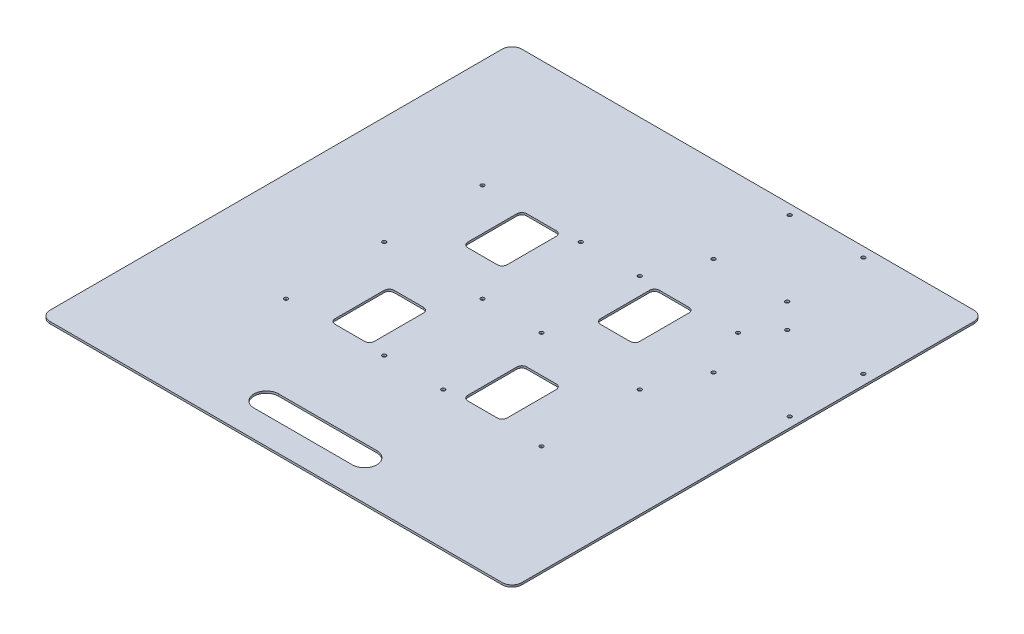
from build123d import *

# Parameters (mm, degrees)
SKETCH1_W                        = 609.6
SKETCH1_H                        = 609.6
BOSS_EXTRUDE1_DEPTH              = 2.65684
CUT_EXTRUDE1_DEPTH               = 3.65684
SKETCH3_R                        = 2.3876
CUT_EXTRUDE2_DEPTH               = 3.65684
LPATTERN1_COUNT                  = 2
LPATTERN1_PITCH                  = 203.2
CUT_EXTRUDE3_DEPTH               = 3.65684
FILLET1_R                        = 12.7
SKETCH5_R                        = 2.3876
CUT_EXTRUDE4_DEPTH               = 3.65684
F_10_0_1935_DIAMETER_HOLE1_D     = 4.9149
F_10_0_1935_DIAMETER_HOLE1_DEPTH = 2.65684


with BuildPart() as part:
    # Sketch1 → Boss-Extrude1 (new body)
    with BuildSketch(Plane(origin=(0, 0, 0), x_dir=(1, 0, 0), z_dir=(0, 1, 0))):
        Rectangle(SKETCH1_W, SKETCH1_H)
    extrude(amount=BOSS_EXTRUDE1_DEPTH)

    # Sketch2 → Cut-Extrude1 (cut, through all)
    with BuildSketch(Plane(origin=(0, 2.65684, 0), x_dir=(1, 0, 0), z_dir=(0, 1, 0))):
        with BuildLine():
            Line((-104.775, 123.825), (-66.675, 123.825))
            ThreePointArc((-66.675, 123.825), (-62.184871939, 121.965128061), (-60.325, 117.475))
            Line((-60.325, 117.475), (-60.325, 53.975))
            ThreePointArc((-60.325, 53.975), (-62.184871939, 49.484871939), (-66.675, 47.625))
            Line((-66.675, 47.625), (-104.775, 47.625))
            ThreePointArc((-104.775, 47.625), (-109.265128061, 49.484871939), (-111.125, 53.975))
            Line((-111.125, 53.975), (-111.125, 117.475))
            ThreePointArc((-111.125, 117.475), (-109.265128061, 121.965128061), (-104.775, 123.825))
        make_face()
        with BuildLine():
            Line((-104.775, -47.625), (-66.675, -47.625))
            ThreePointArc((-66.675, -47.625), (-62.184871939, -49.484871939), (-60.325, -53.975))
            Line((-60.325, -53.975), (-60.325, -117.475))
            ThreePointArc((-60.325, -117.475), (-62.184871939, -121.965128061), (-66.675, -123.825))
            Line((-66.675, -123.825), (-104.775, -123.825))
            ThreePointArc((-104.775, -123.825), (-109.265128061, -121.965128061), (-111.125, -117.475))
            Line((-111.125, -117.475), (-111.125, -53.975))
            ThreePointArc((-111.125, -53.975), (-109.265128061, -49.484871939), (-104.775, -47.625))
        make_face()
        with BuildLine():
            Line((66.675, -47.625), (104.775, -47.625))
            ThreePointArc((104.775, -47.625), (109.265128061, -49.484871939), (111.125, -53.975))
            Line((111.125, -53.975), (111.125, -117.475))
            ThreePointArc((111.125, -117.475), (109.265128061, -121.965128061), (104.775, -123.825))
            Line((104.775, -123.825), (66.675, -123.825))
            ThreePointArc((66.675, -123.825), (62.184871939, -121.965128061), (60.325, -117.475))
            Line((60.325, -117.475), (60.325, -53.975))
            ThreePointArc((60.325, -53.975), (62.184871939, -49.484871939), (66.675, -47.625))
        make_face()
        with BuildLine():
            Line((104.775, 123.825), (66.675, 123.825))
            ThreePointArc((66.675, 123.825), (62.184871939, 121.965128061), (60.325, 117.475))
            Line((60.325, 117.475), (60.325, 53.975))
            ThreePointArc((60.325, 53.975), (62.184871939, 49.484871939), (66.675, 47.625))
            Line((66.675, 47.625), (104.775, 47.625))
            ThreePointArc((104.775, 47.625), (109.265128061, 49.484871939), (111.125, 53.975))
            Line((111.125, 53.975), (111.125, 117.475))
            ThreePointArc((111.125, 117.475), (109.265128061, 121.965128061), (104.775, 123.825))
        make_face()
    extrude(amount=-CUT_EXTRUDE1_DEPTH, mode=Mode.SUBTRACT)

    # Sketch3 → Cut-Extrude2 (cut, through all)
    with BuildSketch(Plane(origin=(0, 2.65684, 0), x_dir=(1, 0, 0), z_dir=(0, 1, 0))):
        with Locations((-165.1, 127)):
            Circle(SKETCH3_R)
        with Locations((-165.1, 0)):
            Circle(SKETCH3_R)
        with Locations((-165.1, -127)):
            Circle(SKETCH3_R)
        with Locations((-38.1, 127)):
            Circle(SKETCH3_R)
        with Locations((-38.1, 0)):
            Circle(SKETCH3_R)
        with Locations((-38.1, -127)):
            Circle(SKETCH3_R)
    cut_extrude2 = extrude(amount=-CUT_EXTRUDE2_DEPTH, mode=Mode.SUBTRACT)

    # LPattern1: Cut-Extrude2 ×2
    with Locations(*[(i * LPATTERN1_PITCH, 0, 0) for i in range(1, LPATTERN1_COUNT)]):
        add(cut_extrude2, mode=Mode.SUBTRACT)

    # Sketch4 → Cut-Extrude3 (cut, through all)
    with BuildSketch(Plane(origin=(0, 2.65684, 0), x_dir=(1, 0, 0), z_dir=(0, 1, 0))):
        with BuildLine():
            Line((-63.5, -238.125), (63.5, -238.125))
            ThreePointArc((63.5, -238.125), (79.375, -254), (63.5, -269.875))
            Line((63.5, -269.875), (-63.5, -269.875))
            ThreePointArc((-63.5, -269.875), (-79.375, -254), (-63.5, -238.125))
        make_face()
    extrude(amount=-CUT_EXTRUDE3_DEPTH, mode=Mode.SUBTRACT)

    # Fillet1
    fillet1_edges = [part.edges().sort_by_distance(p)[0] for p in [
        (304.8, 1.32842, 304.8),
        (-304.8, 1.32842, 304.8),
        (-304.8, 1.32842, -304.8),
        (304.8, 1.32842, -304.8),
    ]]
    fillet(fillet1_edges, radius=FILLET1_R)

    # Sketch5 → Cut-Extrude4 (cut, through all)
    with BuildSketch(Plane(origin=(0, 2.65684, 0), x_dir=(1, 0, 0), z_dir=(0, 1, 0))):
        with Locations((161.925, 292.1)):
            Circle(SKETCH5_R)
        with Locations((66.675, 292.1)):
            Circle(SKETCH5_R)
        with Locations((161.925, 193.675)):
            Circle(SKETCH5_R)
        with Locations((66.675, 193.675)):
            Circle(SKETCH5_R)
        with Locations((193.675, 161.925)):
            Circle(SKETCH5_R)
        with Locations((193.675, 66.675)):
            Circle(SKETCH5_R)
        with Locations((292.1, 66.675)):
            Circle(SKETCH5_R)
        with Locations((292.1, 161.925)):
            Circle(SKETCH5_R)
    extrude(amount=-CUT_EXTRUDE4_DEPTH, mode=Mode.SUBTRACT)

    # #10 (0.1935) Diameter Hole1
    with Locations(Plane(origin=(0, 2.65684, 0), x_dir=(1, 0, 0), z_dir=(0, 1, 0))):
        with Locations((161.925, 292.1), (66.675, 292.1), (292.1, 161.925), (193.675, 161.925), (161.925, 193.675), (66.675, 193.675), (165.1, 127), (38.1, 127), (-38.1, 127), (292.1, 66.675), (193.675, 66.675), (165.1, 0), (165.1, -127), (-38.1, 0), (38.1, 0), (38.1, -127), (-38.1, -127), (-165.1, -127), (-165.1, 0), (-165.1, 127)):
            Hole(F_10_0_1935_DIAMETER_HOLE1_D / 2, depth=F_10_0_1935_DIAMETER_HOLE1_DEPTH)


solid = part.part
